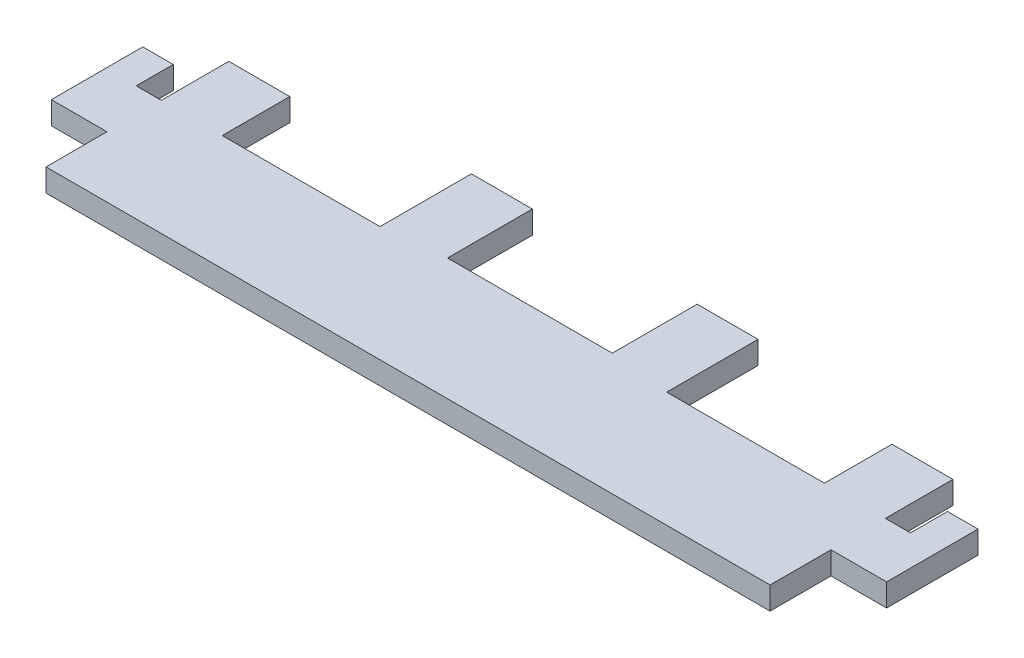
from build123d import *

# Parameters (mm, degrees)
BOSS_EXTRUDE1_DEPTH = 2.3622
SKETCH2_W           = 3.175
SKETCH2_H           = 3.175
CUT_EXTRUDE1_DEPTH  = 2.54


with BuildPart() as part:
    # Sketch1 → Boss-Extrude1 (new body)
    with BuildSketch(Plane(origin=(0, 0, 0), x_dir=(1, 0, 0), z_dir=(0, 1, 0))):
        Polygon((5.7912, 6.35), (5.7912, 19.05), (2.6162, 19.05), (2.6162, 12.0142), (0, 12.0142), (0, 19.05), (-6.35, 19.05), (-6.35, 12.0142), (-22.7838, 12.0142), (-22.7838, 21.5392), (-29.1338, 21.5392), (-29.1338, 12.7), (-46.3042, 12.7), (-46.3042, 21.5392), (-52.6542, 21.5392), (-52.6542, 12.0142), (-69.088, 12.0142), (-69.088, 19.05), (-75.438, 19.05), (-75.438, 12.0142), (-78.0542, 12.0142), (-78.0542, 19.05), (-81.2292, 19.05), (-81.2292, 6.35), (-75.438, 6.35), (-75.438, 0), (0, 0), (0, 6.35), align=None)
    extrude(amount=BOSS_EXTRUDE1_DEPTH)

    # Sketch2 → Cut-Extrude1 (cut)
    with BuildSketch(Plane(origin=(0, 2.3622, 0), x_dir=(1, 0, 0), z_dir=(0, 1, 0))):
        with Locations((4.2037, 17.4625)):
            Rectangle(SKETCH2_W, SKETCH2_H)
        with Locations((-79.6417, 17.4625)):
            Rectangle(SKETCH2_W, SKETCH2_H)
    extrude(amount=-CUT_EXTRUDE1_DEPTH, mode=Mode.SUBTRACT)


solid = part.part
